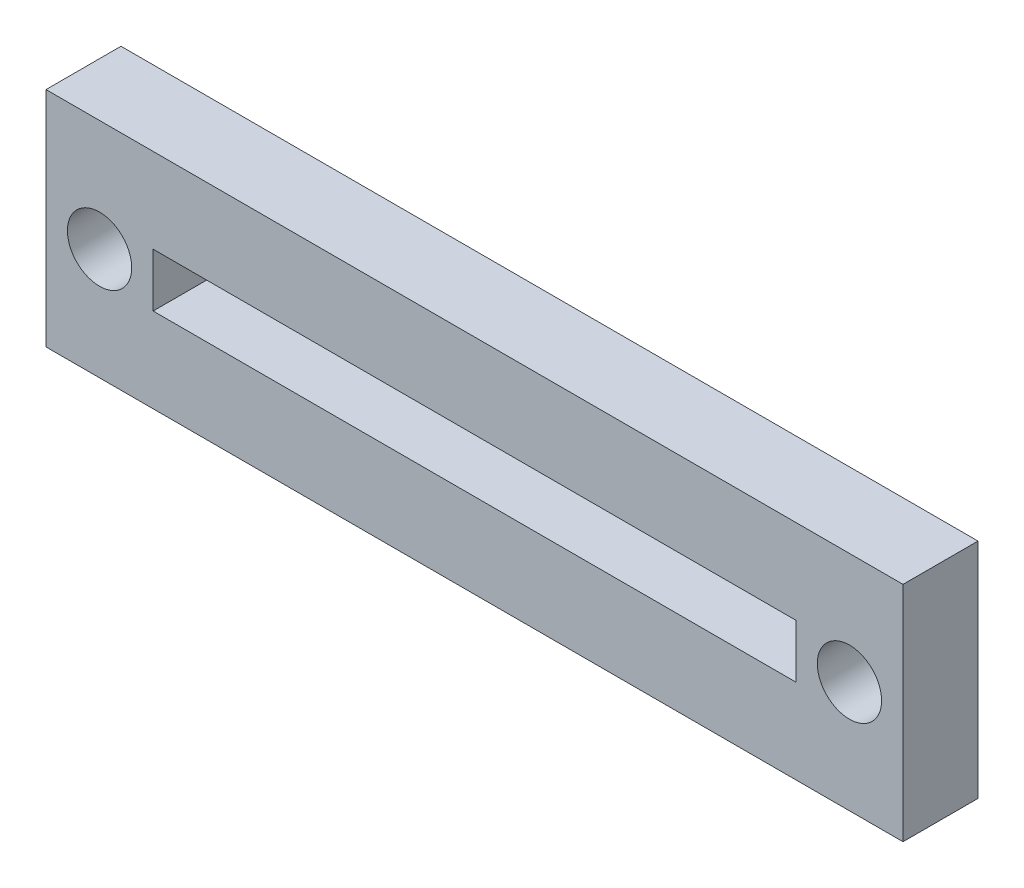
from build123d import *

# Parameters (mm, degrees)
SKETCH1_W           = 40
SKETCH1_H           = 10.404209308
SKETCH1_R           = 1.5
SKETCH1_W_2         = 30
SKETCH1_H_2         = 2.5
BOSS_EXTRUDE1_DEPTH = 3.5


with BuildPart() as part:
    # Sketch1 → Boss-Extrude1 (new body)
    with BuildSketch(Plane(origin=(0, 0, 0), x_dir=(-1, 0, 0), z_dir=(0, 0, -1))):
        with Locations((20, 0)):
            Rectangle(SKETCH1_W, SKETCH1_H)
        with Locations((2.5, 0)):
            Circle(SKETCH1_R, mode=Mode.SUBTRACT)
        with Locations((37.5, 0)):
            Circle(SKETCH1_R, mode=Mode.SUBTRACT)
        with Locations((20, 0)):
            Rectangle(SKETCH1_W_2, SKETCH1_H_2, mode=Mode.SUBTRACT)
    extrude(amount=BOSS_EXTRUDE1_DEPTH)


solid = part.part
